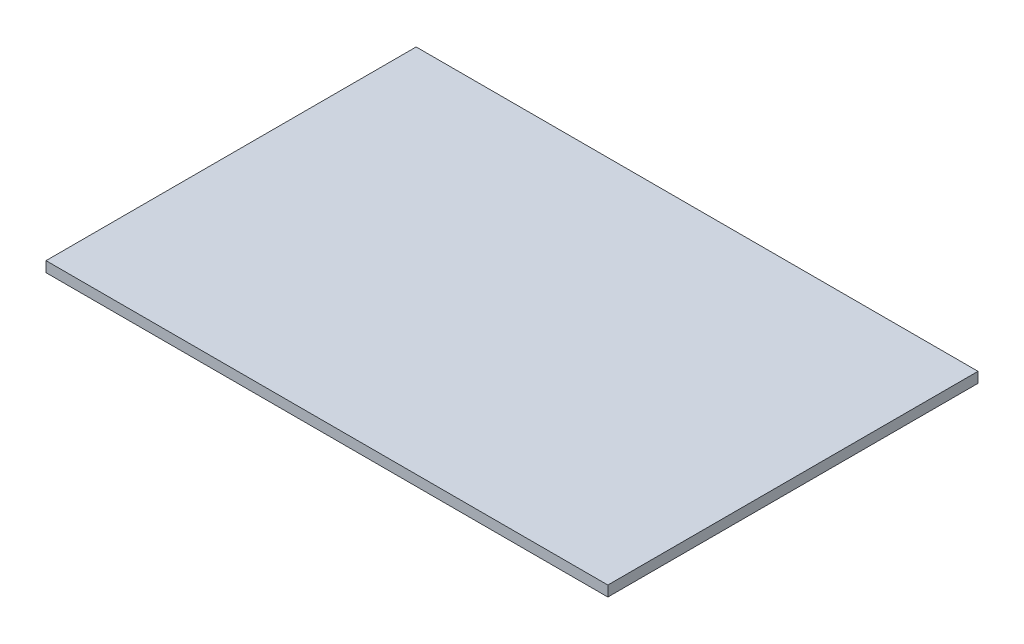
from build123d import *

# Parameters (mm, degrees)
SKETCH1_W           = 1079.5
SKETCH1_H           = 711.2
BOSS_EXTRUDE1_DEPTH = 20.066


with BuildPart() as part:
    # Sketch1 → Boss-Extrude1 (new body)
    with BuildSketch(Plane(origin=(0, 0, 0), x_dir=(1, 0, 0), z_dir=(0, 1, 0))):
        Rectangle(SKETCH1_W, SKETCH1_H)
    extrude(amount=BOSS_EXTRUDE1_DEPTH)


solid = part.part
